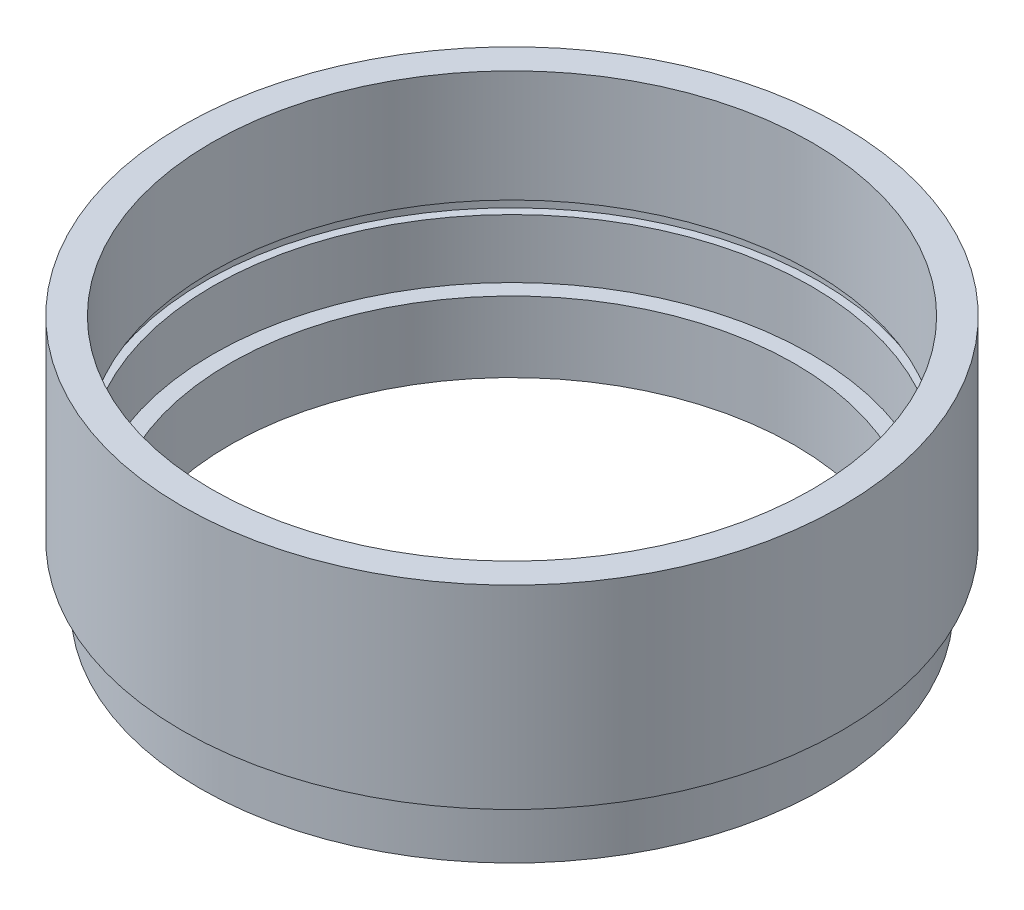
from build123d import *


with BuildPart() as part:
    # 草图1 → 旋转1 (revolve)
    with BuildSketch(Plane.XY, mode=Mode.PRIVATE) as revolve_1_sk:
        Polygon((24, 0), (26.5, 0), (26.5, 4), (25.5, 4), (25.5, 5), (28, 5), (28, 21.5), (25.5, 21.5), (25.5, 12), (26.1, 12), (26.1, 11), (25.4, 11), (25.4, 6), (24, 6), align=None)
    revolve(revolve_1_sk.sketch.rotate(Axis((0, 0, 0), (0, 1, 0)), 90), axis=Axis((0, 0, 0), (0, 1, 0)))  # turned: the seam where the file's is


solid = part.part
